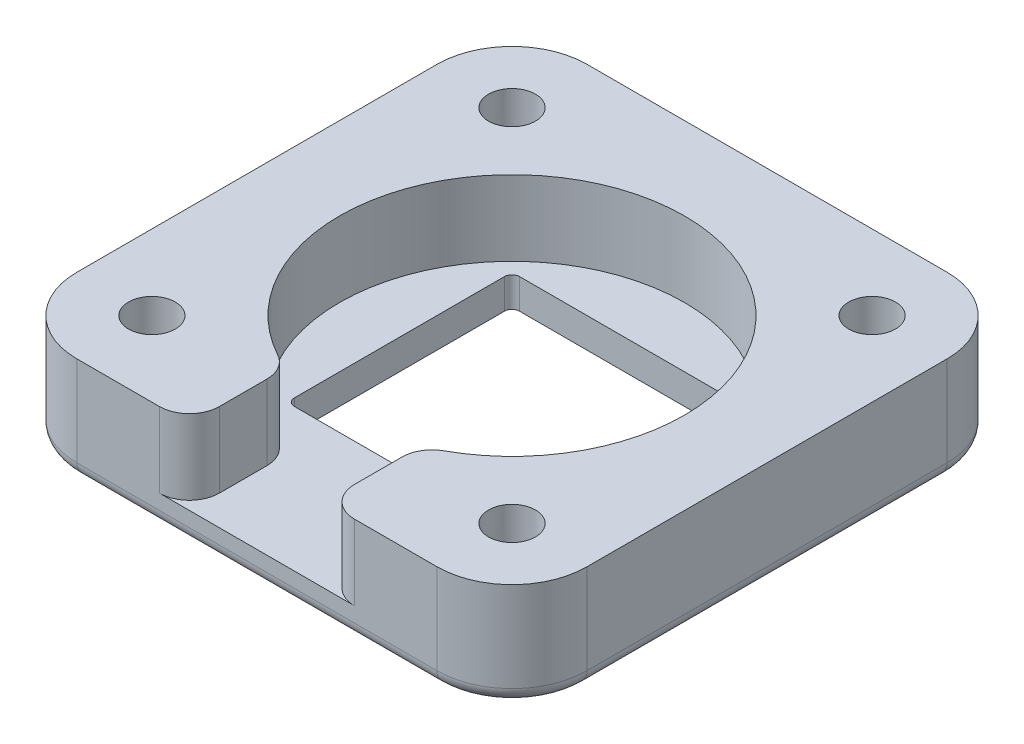
from build123d import *

# Parameters (mm, degrees)
SKETCH1_W           = 34
SKETCH1_H           = 34
BOSS_EXTRUDE1_DEPTH = 7
SKETCH2_R           = 11.5
CUT_EXTRUDE1_DEPTH  = 5
SKETCH3_R           = 1.5621
CUT_EXTRUDE2_DEPTH  = 8
SKETCH4_W           = 9
SKETCH4_H           = 12.899537492
CUT_EXTRUDE3_DEPTH  = 5
SKETCH5_R           = 2.6
CUT_EXTRUDE4_DEPTH  = 4
FILLET1_R           = 5
FILLET2_R           = 1
FILLET3_R           = 2
SKETCH6_W           = 15
SKETCH6_H           = 15
CUT_EXTRUDE5_DEPTH  = 2
FILLET6_R           = 0.5


with BuildPart() as part:
    # Sketch1 → Boss-Extrude1 (new body)
    with BuildSketch(Plane(origin=(0, 0, 0), x_dir=(1, 0, 0), z_dir=(0, 1, 0))):
        with Locations((-0.609342113, -3.800882142)):
            Rectangle(SKETCH1_W, SKETCH1_H)
    extrude(amount=BOSS_EXTRUDE1_DEPTH)

    # Sketch2 → Cut-Extrude1 (cut)
    with BuildSketch(Plane(origin=(0, 7, 0), x_dir=(1, 0, 0), z_dir=(0, 1, 0))):
        with Locations((-0.609342113, -3.800882142)):
            Circle(SKETCH2_R)
    extrude(amount=-CUT_EXTRUDE1_DEPTH, mode=Mode.SUBTRACT)

    # Sketch3 → Cut-Extrude2 (cut, through all)
    with BuildSketch(Plane(origin=(0, 7, 0), x_dir=(1, 0, 0), z_dir=(0, 1, 0))):
        with Locations((-12.609342113, 8.199117858)):
            Circle(SKETCH3_R)
        with Locations((-12.609342113, -15.800882142)):
            Circle(SKETCH3_R)
        with Locations((11.390657887, -15.800882142)):
            Circle(SKETCH3_R)
        with Locations((11.390657887, 8.199117858)):
            Circle(SKETCH3_R)
    extrude(amount=-CUT_EXTRUDE2_DEPTH, mode=Mode.SUBTRACT)

    # Sketch4 → Cut-Extrude3 (cut)
    with BuildSketch(Plane(origin=(0, 7, 0), x_dir=(1, 0, 0), z_dir=(0, 1, 0))):
        with Locations((-0.609342113, -16.792376967)):
            Rectangle(SKETCH4_W, SKETCH4_H)
    extrude(amount=-CUT_EXTRUDE3_DEPTH, mode=Mode.SUBTRACT)

    # Sketch5 → Cut-Extrude4 (cut)
    with BuildSketch(Plane.XZ):
        with Locations((-12.609342113, 15.800882142)):
            Circle(SKETCH5_R)
        with Locations((11.390657887, 15.800882142)):
            Circle(SKETCH5_R)
        with Locations((-12.609342113, -8.199117858)):
            Circle(SKETCH5_R)
        with Locations((11.390657887, -8.199117858)):
            Circle(SKETCH5_R)
    extrude(amount=-CUT_EXTRUDE4_DEPTH, mode=Mode.SUBTRACT)

    # Fillet1
    fillet1_edges = [part.edges().sort_by_distance(p)[0] for p in [
        (-17.609342113, 3.5, -13.199117858),
        (16.390657887, 3.5, -13.199117858),
        (16.390657887, 3.5, 20.800882142),
        (-17.609342113, 3.5, 20.800882142),
    ]]
    fillet(fillet1_edges, radius=FILLET1_R)

    # Fillet2
    fillet2_edges = [part.edges().sort_by_distance(p)[0] for p in [
        (-15.209342113, 0, 15.800882142),
        (8.790657887, 0, 15.800882142),
        (-15.209342113, 0, -8.199117858),
        (8.790657887, 0, -8.199117858),
        (16.390657887, 0, 3.800882142),
        (-17.609342113, 0, 3.800882142),
        (-0.609342113, 0, -13.199117858),
        (-0.609342113, 0, 20.800882142),
        (-16.144876019, 0, 19.336416048),
        (-16.144876019, 0, -11.734651764),
        (14.926191793, 0, -11.734651764),
        (14.926191793, 0, 19.336416048),
    ]]
    fillet(fillet2_edges, radius=FILLET2_R)

    # Fillet3
    fillet3_edges = [part.edges().sort_by_distance(p)[0] for p in [
        (-5.109342113, 4.5, 20.800882142),
        (-5.109342113, 4.5, 14.383887386),
        (3.890657887, 4.5, 20.800882142),
        (3.890657887, 4.5, 14.383887386),
    ]]
    fillet(fillet3_edges, radius=FILLET3_R)

    # Sketch6 → Cut-Extrude5 (cut)
    with BuildSketch(Plane.XZ):
        with Locations((-0.609342113, 3.800882142)):
            Rectangle(SKETCH6_W, SKETCH6_H)
    extrude(amount=-CUT_EXTRUDE5_DEPTH, mode=Mode.SUBTRACT)

    # Fillet6
    fillet6_edges = [part.edges().sort_by_distance(p)[0] for p in [
        (-8.109342113, 1, -3.699117858),
        (-8.109342113, 1, 11.300882142),
        (6.890657887, 1, 11.300882142),
        (6.890657887, 1, -3.699117858),
    ]]
    fillet(fillet6_edges, radius=FILLET6_R)


solid = part.part
